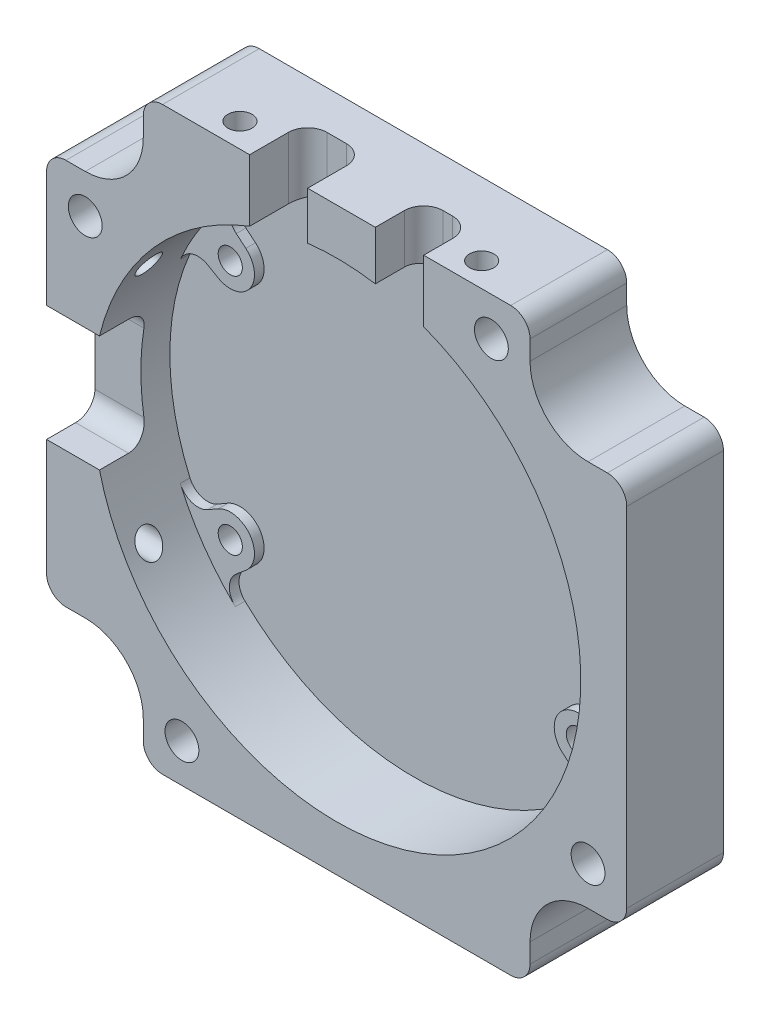
from build123d import *

# Parameters (mm, degrees)
SKETCH_1_W             = 60
SKETCH_1_H             = 60
EXTRUDE_1_DEPTH        = 10
SKETCH_2_R             = 25.25
CUT_EXTRUDE_1_DEPTH    = 8
SKETCH_4_W             = 10
SKETCH_4_H             = 10
CUT_EXTRUDE_3_DEPTH    = 11
FILLET_1_R             = 6
FILLET_2_R             = 2
SKETCH_5_R             = 1.75
CUT_EXTRUDE_4_DEPTH    = 11
EXTRUDE_2_DEPTH        = 1
FILLET_5_R             = 2
HOLE_WIZARD_M3_2_D     = 2.5
HOLE_WIZARD_M3_2_DEPTH = 7.5
HOLE_WIZARD_M3_2_TIP   = 0.751075774
SKETCH_21_R            = 1.25
SKETCH_21_W            = 5
SKETCH_21_H            = 5
SKETCH_21_W_2          = 6
SKETCH_21_H_2          = 6
CUT_EXTRUDE_9_DEPTH    = 10
SKETCH_23_R            = 1.25
SKETCH_23_W            = 5
SKETCH_23_H            = 12
CUT_EXTRUDE_10_DEPTH   = 10
SKETCH_25_R            = 2.75
CUT_EXTRUDE_11_DEPTH   = 3
FILLET_6_R             = 2


with BuildPart() as part:
    # 草图1 → 凸台-拉伸1 (new body)
    with BuildSketch(Plane.XY):
        with Locations((30, -30)):
            Rectangle(SKETCH_1_W, SKETCH_1_H)
    extrude(amount=EXTRUDE_1_DEPTH)

    # 草图2 → 切除-拉伸1 (cut)
    with BuildSketch(Plane.XY.offset(10)):
        with Locations((30, -30)):
            Circle(SKETCH_2_R)
    extrude(amount=-CUT_EXTRUDE_1_DEPTH, mode=Mode.SUBTRACT)

    # 草图4 → 切除-拉伸3 (cut, through all)
    with BuildSketch(Plane(origin=(0, 0, 0), x_dir=(-1, 0, 0), z_dir=(0, 0, -1))):
        with Locations((-5, -5)):
            Rectangle(SKETCH_4_W, SKETCH_4_H)
        with Locations((-55, -5)):
            Rectangle(SKETCH_4_W, SKETCH_4_H)
        with Locations((-5, -55)):
            Rectangle(SKETCH_4_W, SKETCH_4_H)
        with Locations((-55, -55)):
            Rectangle(SKETCH_4_W, SKETCH_4_H)
    extrude(amount=-CUT_EXTRUDE_3_DEPTH, mode=Mode.SUBTRACT)

    # 圆角1
    fillet_1_edges = [part.edges().sort_by_distance(p)[0] for p in [
        (50, -50, 5),
        (10, -50, 5),
        (10, -10, 5),
        (50, -10, 5),
    ]]
    fillet(fillet_1_edges, radius=FILLET_1_R)

    # 圆角2
    fillet_2_edges = [part.edges().sort_by_distance(p)[0] for p in [
        (60, -50, 5),
        (50, -60, 5),
        (0, -50, 5),
        (10, -60, 5),
        (10, 0, 5),
        (0, -10, 5),
        (60, -10, 5),
        (50, 0, 5),
    ]]
    fillet(fillet_2_edges, radius=FILLET_2_R)

    # 草图5 → 切除-拉伸4 (cut, through all)
    with BuildSketch(Plane(origin=(0, 0, 0), x_dir=(-1, 0, 0), z_dir=(0, 0, -1))):
        with Locations((-4, -14)):
            Circle(SKETCH_5_R)
        with Locations((-14, -56)):
            Circle(SKETCH_5_R)
        with Locations((-56, -46)):
            Circle(SKETCH_5_R)
        with Locations((-46, -4)):
            Circle(SKETCH_5_R)
    extrude(amount=-CUT_EXTRUDE_4_DEPTH, mode=Mode.SUBTRACT)

    # 草图15 → 凸台-拉伸2 (add)
    with BuildSketch(Plane.XY.offset(2)):
        with BuildLine():
            Line((46.393030976, -15.584888892), (49.013896395, -13.385721686))
            ThreePointArc((49.013896395, -13.385721686), (50.732040439, -15.58663817), (52.196675107, -17.963799843))
            Line((52.196675107, -17.963799843), (49.25, -19.665063509))
            ThreePointArc((49.25, -19.665063509), (45.952119889, -18.933941091), (46.393030976, -15.584888892))
        make_face()
        with BuildLine():
            Line((13.606969024, -15.584888892), (10.986103605, -13.385721686))
            ThreePointArc((10.986103605, -13.385721686), (9.267959561, -15.58663817), (7.803324893, -17.963799843))
            Line((7.803324893, -17.963799843), (10.75, -19.665063509))
            ThreePointArc((10.75, -19.665063509), (14.047880111, -18.933941091), (13.606969024, -15.584888892))
        make_face()
        with BuildLine():
            Line((46.393030976, -44.415111108), (49.013896395, -46.614278314))
            ThreePointArc((49.013896395, -46.614278314), (50.732040439, -44.41336183), (52.196675107, -42.036200157))
            Line((52.196675107, -42.036200157), (49.25, -40.334936491))
            ThreePointArc((49.25, -40.334936491), (45.952119889, -41.066058909), (46.393030976, -44.415111108))
        make_face()
        with BuildLine():
            Line((10.75, -40.334936491), (7.803324893, -42.036200157))
            ThreePointArc((7.803324893, -42.036200157), (9.267959561, -44.41336183), (10.986103605, -46.614278314))
            Line((10.986103605, -46.614278314), (13.606969024, -44.415111108))
            ThreePointArc((13.606969024, -44.415111108), (14.047880111, -41.066058909), (10.75, -40.334936491))
        make_face()
    extrude(amount=EXTRUDE_2_DEPTH)

    # 圆角5
    fillet_5_edges = [part.edges().sort_by_distance(p)[0] for p in [
        (10.986103605, -13.385721686, 2.5),
        (7.803324893, -17.963799843, 2.5),
        (52.196675107, -17.963799843, 2.5),
        (49.013896395, -13.385721686, 2.5),
        (49.013896395, -46.614278314, 2.5),
        (52.196675107, -42.036200157, 2.5),
        (7.803324893, -42.036200157, 2.5),
        (10.986103605, -46.614278314, 2.5),
    ]]
    fillet(fillet_5_edges, radius=FILLET_5_R)

    # M3 螺纹孔2
    with Locations(Plane.XY.offset(3)):
        with Locations((12, -17.5), (12, -42.5), (48, -17.5), (48, -42.5)):
            Hole(HOLE_WIZARD_M3_2_D / 2, depth=HOLE_WIZARD_M3_2_DEPTH)
            with Locations((0, 0, -(HOLE_WIZARD_M3_2_DEPTH + HOLE_WIZARD_M3_2_TIP / 2))):  # 118° drill point
                Cone(0, HOLE_WIZARD_M3_2_D / 2, HOLE_WIZARD_M3_2_TIP, mode=Mode.SUBTRACT)

    # 草图21 → 切除-拉伸9 (cut)
    with BuildSketch(Plane(origin=(0, 0, 0), x_dir=(1, 0, 0), z_dir=(0, 1, 0))):
        with Locations((17.5, -7.5)):
            Circle(SKETCH_21_R)
        with Locations((42.5, -7.5)):
            Circle(SKETCH_21_R)
        with Locations((36.5, -7.5)):
            Rectangle(SKETCH_21_W, SKETCH_21_H)
        with Locations((24, -7)):
            Rectangle(SKETCH_21_W_2, SKETCH_21_H_2)
    extrude(amount=-CUT_EXTRUDE_9_DEPTH, mode=Mode.SUBTRACT)

    # 草图23 → 切除-拉伸10 (cut)
    with BuildSketch(Plane.ZY):
        with Locations((7.5, -17.5)):
            Circle(SKETCH_23_R)
        with Locations((7.5, -42.5)):
            Circle(SKETCH_23_R)
        with Locations((7.5, -30)):
            Rectangle(SKETCH_23_W, SKETCH_23_H)
    extrude(amount=-CUT_EXTRUDE_10_DEPTH, mode=Mode.SUBTRACT)

    # 草图25 → 切除-拉伸11 (cut)
    with BuildSketch(Plane(origin=(0, 0, 0), x_dir=(-1, 0, 0), z_dir=(0, 0, -1))):
        with Locations((-4, -14)):
            Circle(SKETCH_25_R)
        with Locations((-46, -4)):
            Circle(SKETCH_25_R)
        with Locations((-56, -46)):
            Circle(SKETCH_25_R)
        with Locations((-14, -56)):
            Circle(SKETCH_25_R)
    extrude(amount=-CUT_EXTRUDE_11_DEPTH, mode=Mode.SUBTRACT)

    # 圆角6
    fillet_6_edges = [part.edges().sort_by_distance(p)[0] for p in [
        (21, -3.204211557, 4),
        (27, -2.464425621, 4),
        (34, -2.534422396, 5),
        (39, -3.204211557, 5),
        (2.736614456, -36, 5),
        (2.736614456, -24, 5),
    ]]
    fillet(fillet_6_edges, radius=FILLET_6_R)


solid = part.part
